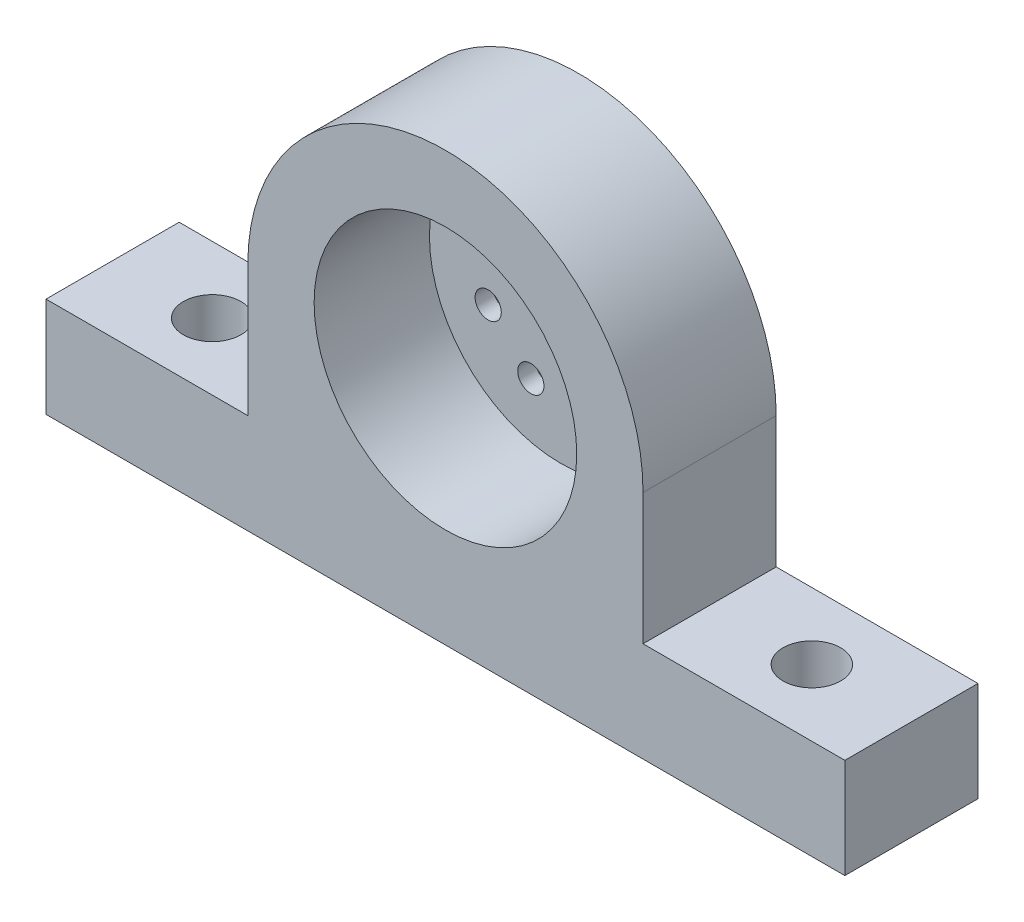
from build123d import *

# Parameters (mm, degrees)
SKETCH1_W             = 152.4
SKETCH1_H             = 19.05
SKETCH1_R             = 4
BOSS_EXTRUDE1_DEPTH   = 25.4
SKETCH3_R             = 25.05
CUT_EXTRUDE1_DEPTH    = 22
M10_CLEARANCE_HOLE1_D = 11
SKETCH11_R            = 2.5
CUT_EXTRUDE2_DEPTH    = 10


with BuildPart() as part:
    # Sketch1 → Boss-Extrude1 (new body)
    with BuildSketch(Plane.XY):
        with Locations((0, -34.525)):
            Rectangle(SKETCH1_W, SKETCH1_H)
        with BuildLine():
            Line((-37.7, -25), (37.7, -25))
            Line((37.7, -25), (37.7, 0))
            ThreePointArc((37.7, 0), (0, 37.7), (-37.7, 0))
            Line((-37.7, 0), (-37.7, -25))
        make_face()
        Circle(SKETCH1_R, mode=Mode.SUBTRACT)
    extrude(amount=BOSS_EXTRUDE1_DEPTH)

    # Sketch3 → Cut-Extrude1 (cut)
    with BuildSketch(Plane.XY.offset(25.4)):
        Circle(SKETCH3_R)
    extrude(amount=-CUT_EXTRUDE1_DEPTH, mode=Mode.SUBTRACT)

    # M10 Clearance Hole1 (through all)
    with Locations(Plane(origin=(0, -25, 0), x_dir=(1, 0, 0), z_dir=(0, 1, 0))):
        with Locations((-57.2, -12.7), (57.2, -12.7)):
            Hole(M10_CLEARANCE_HOLE1_D / 2)

    # Sketch11 → Cut-Extrude2 (cut)
    with BuildSketch(Plane(origin=(0, 0, 0), x_dir=(-1, 0, 0), z_dir=(0, 0, -1))):
        with Locations((5.775120383, 13.84369837)):
            Circle(SKETCH11_R)
        with Locations((-5.705346209, 13.872599779)):
            Circle(SKETCH11_R)
        with Locations((-13.84369837, 5.775120383)):
            Circle(SKETCH11_R)
        with Locations((-13.872599779, -5.705346209)):
            Circle(SKETCH11_R)
        with Locations((-5.775120383, -13.84369837)):
            Circle(SKETCH11_R)
        with Locations((5.705346209, -13.872599779)):
            Circle(SKETCH11_R)
        with Locations((13.84369837, -5.775120383)):
            Circle(SKETCH11_R)
        with Locations((13.872599779, 5.705346209)):
            Circle(SKETCH11_R)
    extrude(amount=-CUT_EXTRUDE2_DEPTH, mode=Mode.SUBTRACT)


solid = part.part
